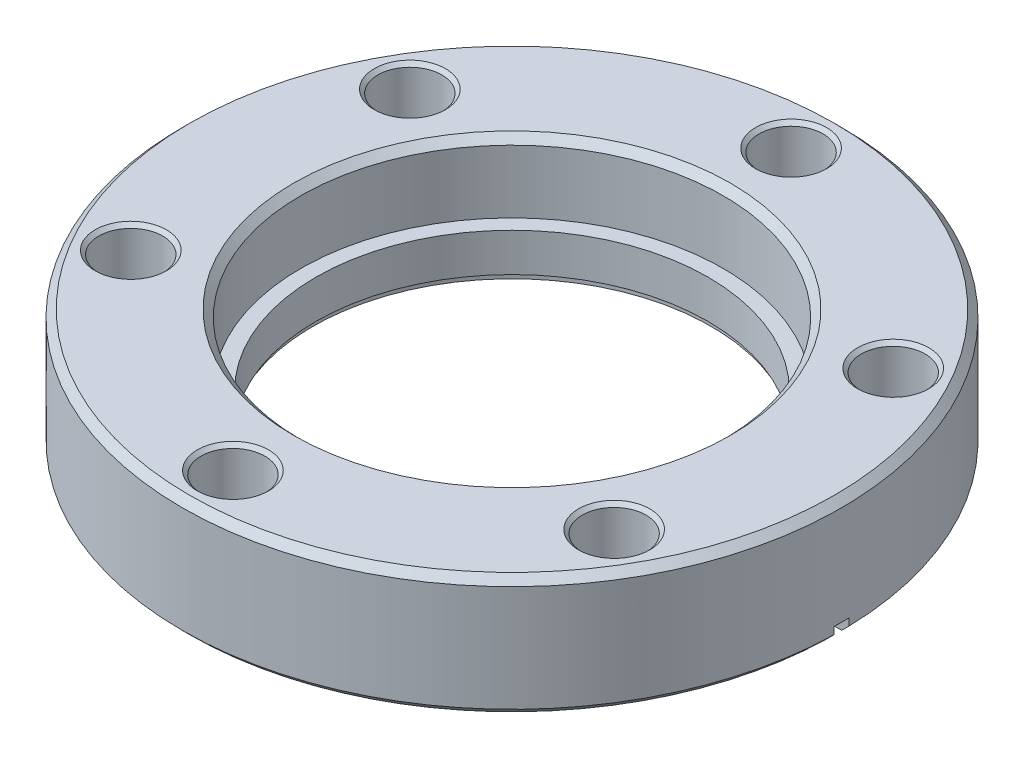
from build123d import *

# Parameters (mm, degrees)
SKETCH1_R                    = 34.671
SKETCH1_R_2                  = 20.6375
BOSS_EXTRUDE1_DEPTH          = 12.7
SKETCH2_R                    = 22.225
CUT_EXTRUDE1_DEPTH           = 7.3914
CHAMFER1_SIZE                = 0.762
SKETCH4_R                    = 3.3655
CUT_EXTRUDE2_DEPTH           = 13.7
CHAMFER2_SIZE                = 0.381
CIRPATTERN1_COUNT            = 6
CHAMFER2_OF_CIRPATTERN1_SIZE = 0.381
CUT_EXTRUDE3_DEPTH           = 0.79375


with BuildPart() as part:
    # Sketch1 → Boss-Extrude1 (new body)
    with BuildSketch(Plane(origin=(0, 0, 0), x_dir=(1, 0, 0), z_dir=(0, 1, 0))):
        Circle(SKETCH1_R)
        Circle(SKETCH1_R_2, mode=Mode.SUBTRACT)
    extrude(amount=BOSS_EXTRUDE1_DEPTH)

    # Sketch2 → Cut-Extrude1 (cut)
    with BuildSketch(Plane(origin=(0, 12.7, 0), x_dir=(1, 0, 0), z_dir=(0, 1, 0))):
        Circle(SKETCH2_R)
    extrude(amount=-CUT_EXTRUDE1_DEPTH, mode=Mode.SUBTRACT)

    # Chamfer1
    chamfer1_edges = [part.edges().sort_by_distance(p)[0] for p in [
        (-22.225, 12.7, 0),
        (-34.671, 0, 0),
        (-34.671, 12.7, 0),
    ]]
    chamfer(chamfer1_edges, length=CHAMFER1_SIZE)

    # Sketch3 → Cut-Revolve1 (revolve, cut)
    with BuildSketch(Plane.XY):
        Polygon((-24.1554, 0), (-24.1554, 1.825244), (-20.955, 0.6604), (-20.955, 1.27), (0, 1.27), (0, 0), align=None)
    revolve(axis=Axis((0, 12.7, 0), (0, -1, 0)), mode=Mode.SUBTRACT)

    # Sketch4 → Cut-Extrude2 (cut, through all)
    with BuildSketch(Plane(origin=(0, 12.7, 0), x_dir=(1, 0, 0), z_dir=(0, 1, 0))):
        with Locations((0, 29.3624)):
            Circle(SKETCH4_R)
    cut_extrude2 = extrude(amount=-CUT_EXTRUDE2_DEPTH, mode=Mode.SUBTRACT)

    # Chamfer2
    chamfer2_edges = [part.edges().sort_by_distance(p)[0] for p in [
        (-3.3655, 0, -29.3624),
        (-3.3655, 12.7, -29.3624),
    ]]
    chamfer(chamfer2_edges, length=CHAMFER2_SIZE)

    # CirPattern1: Cut-Extrude2 ×6 about axis
    cirpattern1_axis = Axis((0, 0, 0), (0, 1, 0))
    for i in range(1, CIRPATTERN1_COUNT):
        add(cut_extrude2.rotate(cirpattern1_axis, i * 360 / CIRPATTERN1_COUNT), mode=Mode.SUBTRACT)

    # Chamfer2 of CirPattern1
    chamfer2_of_cirpattern1_edges = [part.edges().sort_by_distance(p)[0] for p in [
        (-27.111334316, 0, -11.766591504),
        (-27.111334316, 12.7, -11.766591504),
        (-23.745834316, 0, 17.595808496),
        (-23.745834316, 12.7, 17.595808496),
        (3.3655, 0, 29.3624),
        (3.3655, 12.7, 29.3624),
        (27.111334316, 0, 11.766591504),
        (27.111334316, 12.7, 11.766591504),
        (23.745834316, 0, -17.595808496),
        (23.745834316, 12.7, -17.595808496),
    ]]
    chamfer(chamfer2_of_cirpattern1_edges, length=CHAMFER2_OF_CIRPATTERN1_SIZE)

    # Sketch5 → Cut-Extrude3 (cut, symmetric)
    with BuildSketch(Plane.XY):
        Polygon((-23.765182704, 0.94596365), (-35.869388854, 1.580318214), (-35.869388854, -0.2995168), (-23.765182704, -0.2995168), align=None)
        Polygon((23.765182704, 0.94596365), (23.765182704, -0.2995168), (35.869388854, -0.2995168), (35.869388854, 1.580318214), align=None)
    extrude(amount=CUT_EXTRUDE3_DEPTH, both=True, mode=Mode.SUBTRACT)


solid = part.part
